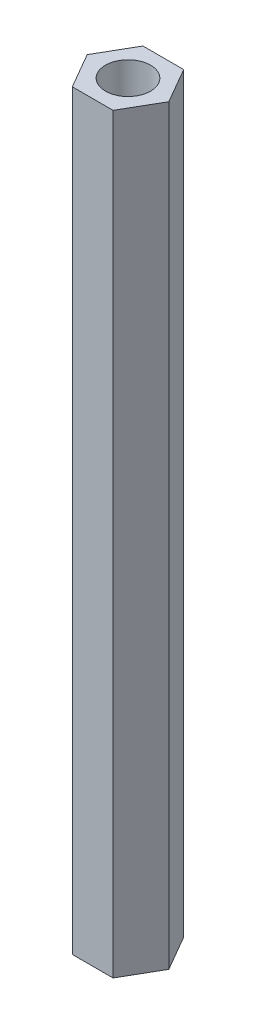
from build123d import *

# Parameters (mm, degrees)
SKETCH2_R           = 1.5
BOSS_EXTRUDE1_DEPTH = 50


with BuildPart() as part:
    # Sketch2 → Boss-Extrude1 (new body)
    with BuildSketch(Plane(origin=(0, 0, 0), x_dir=(1, 0, 0), z_dir=(0, 1, 0))):
        Polygon((2.713546265, 0), (1.356773133, 2.35), (-1.356773133, 2.35), (-2.713546265, 0), (-1.356773133, -2.35), (1.356773133, -2.35), align=None)
        Circle(SKETCH2_R, mode=Mode.SUBTRACT)
    extrude(amount=BOSS_EXTRUDE1_DEPTH)


solid = part.part
